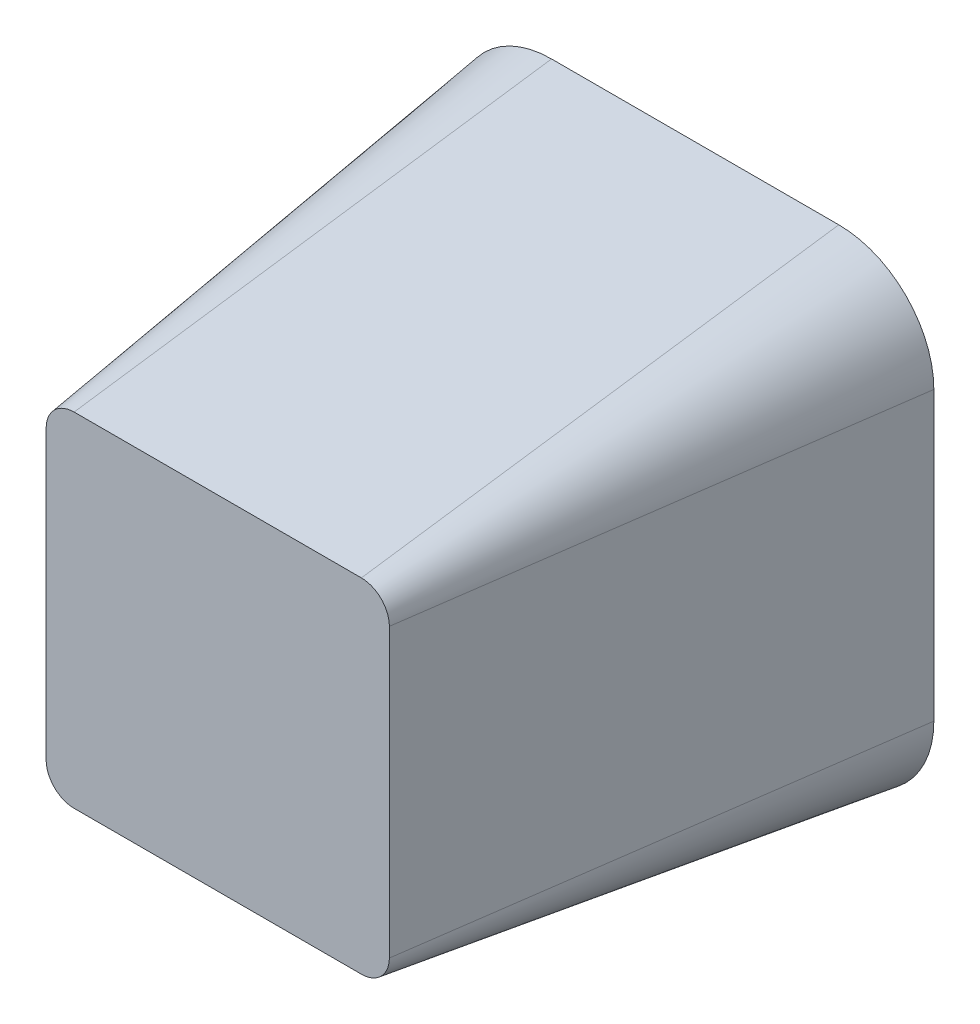
from build123d import *

# Parameters (mm, degrees)
BOSS_EXTRUDE1_DEPTH = 10
BOSS_EXTRUDE1_TAPER = 8


with BuildPart() as part:
    # Sketch1 → Boss-Extrude1 (new body)
    with BuildSketch(Plane.XY):
        with BuildLine():
            ThreePointArc((-6.897446528, 3.888888889), (-8.305608926, 3.305608926), (-8.888888889, 1.897446528))
            Line((-8.888888889, 1.897446528), (-8.888888889, -4.11966875))
            ThreePointArc((-8.888888889, -4.11966875), (-8.305608926, -5.527831148), (-6.897446528, -6.111111111))
            Line((-6.897446528, -6.111111111), (-0.88033125, -6.111111111))
            ThreePointArc((-0.88033125, -6.111111111), (0.527831148, -5.527831148), (1.111111111, -4.11966875))
            Line((1.111111111, -4.11966875), (1.111111111, 1.897446528))
            ThreePointArc((1.111111111, 1.897446528), (0.527831148, 3.305608926), (-0.88033125, 3.888888889))
            Line((-0.88033125, 3.888888889), (-6.897446528, 3.888888889))
        make_face()
    extrude(amount=BOSS_EXTRUDE1_DEPTH, taper=BOSS_EXTRUDE1_TAPER)


solid = part.part
